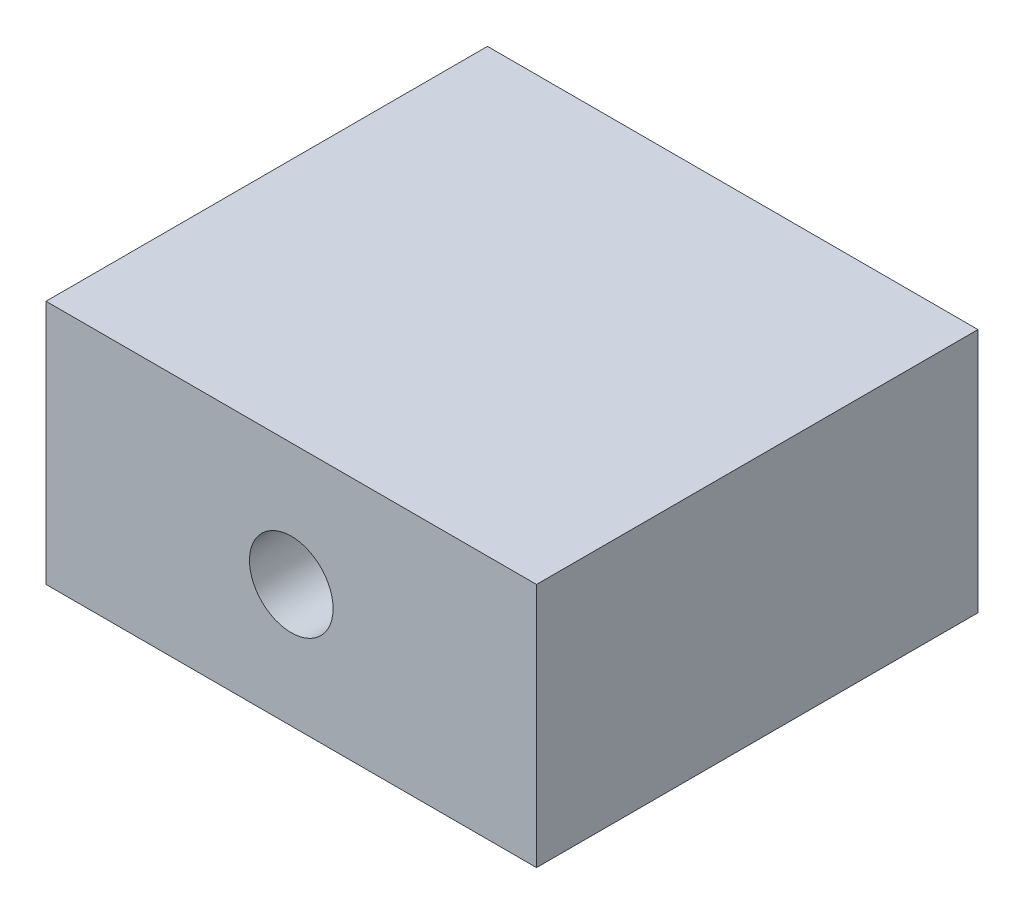
from build123d import *

# Parameters (mm, degrees)
SKETCH1_W           = 20
SKETCH1_H           = 18
BOSS_EXTRUDE1_DEPTH = 10
SKETCH2_R           = 1.705
CUT_EXTRUDE1_DEPTH  = 15
SKETCH3_W           = 7.3
SKETCH3_H           = 8.65
CUT_EXTRUDE2_DEPTH  = 8


with BuildPart() as part:
    # Sketch1 → Boss-Extrude1 (new body)
    with BuildSketch(Plane(origin=(0, 0, 0), x_dir=(1, 0, 0), z_dir=(0, 1, 0))):
        with Locations((-18, -29)):
            Rectangle(SKETCH1_W, SKETCH1_H)
    extrude(amount=BOSS_EXTRUDE1_DEPTH)

    # Sketch2 → Cut-Extrude1 (cut)
    with BuildSketch(Plane.XY.offset(38)):
        with Locations((-18, 5)):
            Circle(SKETCH2_R)
    extrude(amount=-CUT_EXTRUDE1_DEPTH, mode=Mode.SUBTRACT)

    # Sketch3 → Cut-Extrude2 (cut)
    with BuildSketch(Plane.XY.offset(23)):
        with Locations((-18, 4.325)):
            Rectangle(SKETCH3_W, SKETCH3_H)
    extrude(amount=CUT_EXTRUDE2_DEPTH, mode=Mode.SUBTRACT)


solid = part.part
